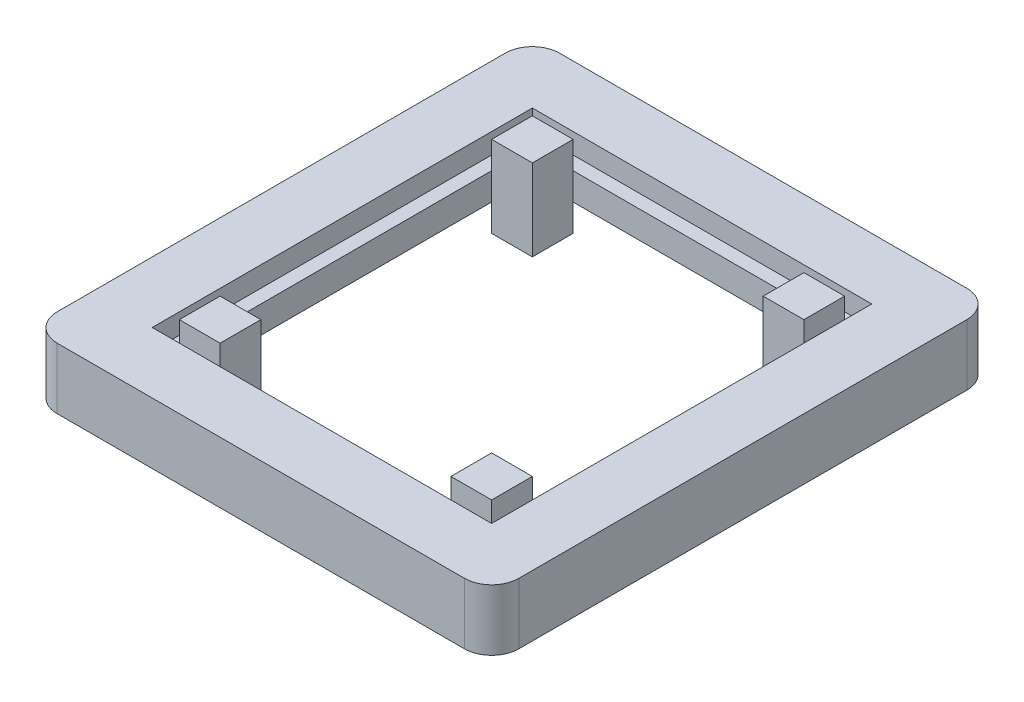
from build123d import *

# Parameters (mm, degrees)
SKETCH1_W                = 635
SKETCH1_H                = 711.2
SKETCH1_W_2              = 584.2
SKETCH1_H_2              = 660.4
BOSS_EXTRUDE2_DEPTH      = 50.8
SKETCH1_3_W              = 76.2
SKETCH1_3_H              = 76.2
BOSS_EXTRUDE3_DEPTH      = 101.6
BOSS_EXTRUDE3_DEPTH_BACK = 50.8
SKETCH3_W                = 863.6
SKETCH3_H                = 939.8
SKETCH3_W_2              = 635
SKETCH3_H_2              = 711.2
BOSS_EXTRUDE4_DEPTH      = 88.9
BOSS_EXTRUDE4_DEPTH_BACK = 25.4
FILLET1_R                = 50.8


with BuildPart() as part:
    # Sketch1 → Boss-Extrude2 (new body)
    with BuildSketch(Plane(origin=(0, 0, 0), x_dir=(1, 0, 0), z_dir=(0, 1, 0))):
        Rectangle(SKETCH1_W, SKETCH1_H)
        Rectangle(SKETCH1_W_2, SKETCH1_H_2, mode=Mode.SUBTRACT)
    extrude(amount=BOSS_EXTRUDE2_DEPTH)

    # Sketch1_3 → Boss-Extrude3 (add, two sides)
    with BuildSketch(Plane(origin=(0, 0, 0), x_dir=(1, 0, 0), z_dir=(0, 1, 0))) as boss_extrude3_sk:
        with Locations((-254, 292.1)):
            Rectangle(SKETCH1_3_W, SKETCH1_3_H)
        with Locations((254, 292.1)):
            Rectangle(SKETCH1_3_W, SKETCH1_3_H)
        with Locations((254, -292.1)):
            Rectangle(SKETCH1_3_W, SKETCH1_3_H)
        with Locations((-254, -292.1)):
            Rectangle(SKETCH1_3_W, SKETCH1_3_H)
    extrude(amount=BOSS_EXTRUDE3_DEPTH)
    extrude(boss_extrude3_sk.sketch, amount=-BOSS_EXTRUDE3_DEPTH_BACK)

    # Sketch3 → Boss-Extrude4 (add, two sides)
    with BuildSketch(Plane(origin=(0, 0, 0), x_dir=(1, 0, 0), z_dir=(0, 1, 0))) as boss_extrude4_sk:
        Rectangle(SKETCH3_W, SKETCH3_H)
        Rectangle(SKETCH3_W_2, SKETCH3_H_2, mode=Mode.SUBTRACT)
    extrude(amount=BOSS_EXTRUDE4_DEPTH)
    extrude(boss_extrude4_sk.sketch, amount=-BOSS_EXTRUDE4_DEPTH_BACK)

    # Fillet1
    fillet1_edges = [part.edges().sort_by_distance(p)[0] for p in [
        (-431.8, 31.75, 469.9),
        (-431.8, 31.75, -469.9),
        (431.8, 31.75, -469.9),
        (431.8, 31.75, 469.9),
    ]]
    fillet(fillet1_edges, radius=FILLET1_R)


solid = part.part
